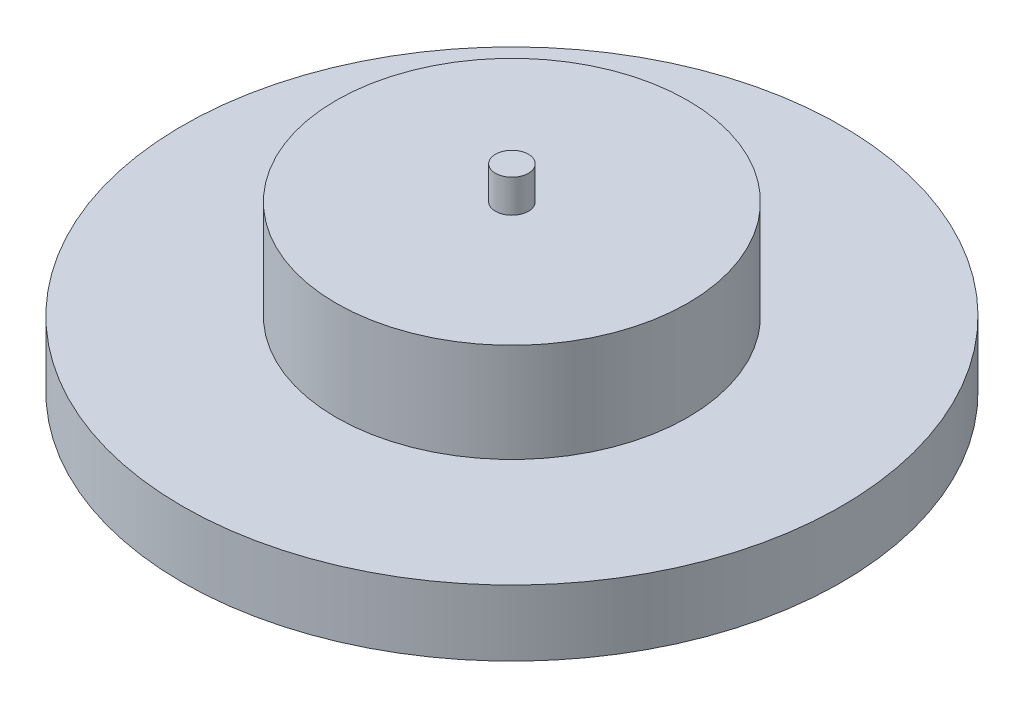
from build123d import *

# Parameters (mm, degrees)
SKETCH_1_R      = 15
EXTRUDE_1_DEPTH = 3
SKETCH_2_R      = 8
EXTRUDE_2_DEPTH = 4.5
SKETCH_3_R      = 0.75
EXTRUDE_3_DEPTH = 1.5


with BuildPart() as part:
    # 草图1 → 凸台-拉伸1 (new body)
    with BuildSketch(Plane(origin=(0, 0, 0), x_dir=(1, 0, 0), z_dir=(0, 1, 0))):
        Circle(SKETCH_1_R)
    extrude(amount=EXTRUDE_1_DEPTH)

    # 草图2 → 凸台-拉伸2 (add)
    with BuildSketch(Plane(origin=(0, 3, 0), x_dir=(1, 0, 0), z_dir=(0, 1, 0))):
        Circle(SKETCH_2_R)
    extrude(amount=EXTRUDE_2_DEPTH)

    # 草图3 → 凸台-拉伸3 (add)
    with BuildSketch(Plane(origin=(0, 7.5, 0), x_dir=(1, 0, 0), z_dir=(0, 1, 0))):
        Circle(SKETCH_3_R)
    extrude(amount=EXTRUDE_3_DEPTH)


solid = part.part
